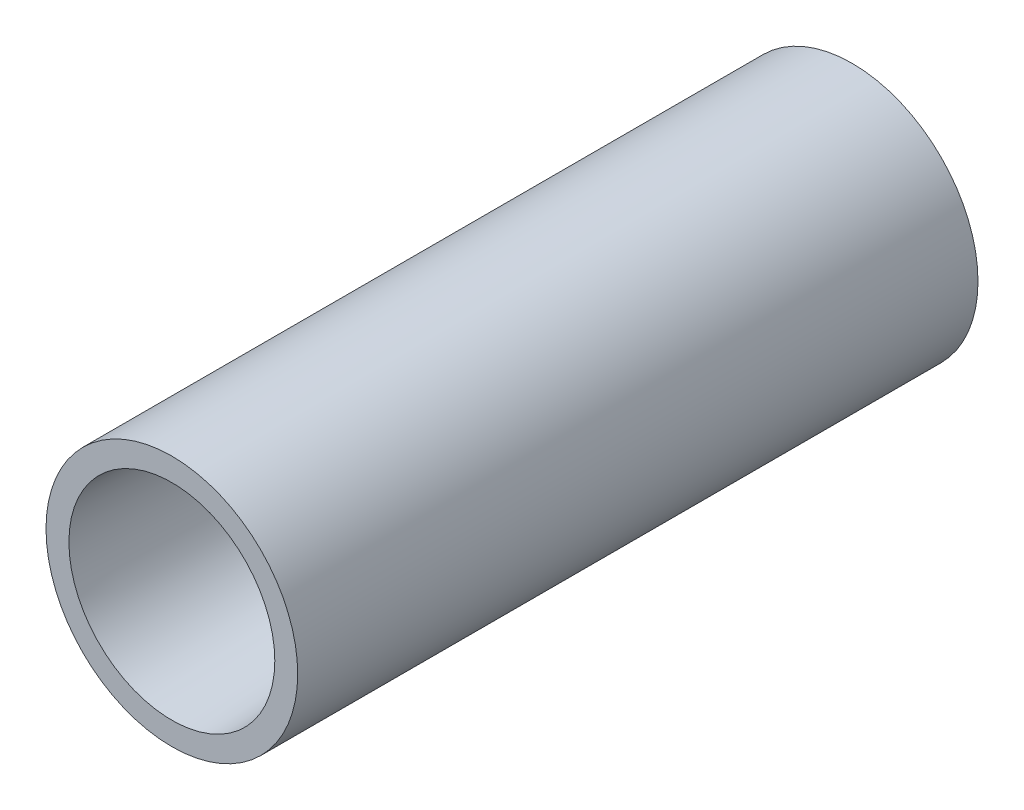
from build123d import *

# Parameters (mm, degrees)
SKETCH1_R           = 2.775
BOSS_EXTRUDE1_DEPTH = 15
SKETCH2_R           = 2.27
CUT_EXTRUDE1_DEPTH  = 5.68
CUT_EXTRUDE1_TAPER  = 3.074
SKETCH7_R           = 1
CUT_EXTRUDE2_DEPTH  = 16
SKETCH9_R           = 2.27
CUT_EXTRUDE3_DEPTH  = 5.68
CUT_EXTRUDE3_TAPER  = 3.074


with BuildPart() as part:
    # Sketch1 → Boss-Extrude1 (new body)
    with BuildSketch(Plane.XY):
        Circle(SKETCH1_R)
    extrude(amount=BOSS_EXTRUDE1_DEPTH)

    # Sketch2 → Cut-Extrude1 (cut)
    with BuildSketch(Plane.XY):
        Circle(SKETCH2_R)
    extrude(amount=CUT_EXTRUDE1_DEPTH, taper=CUT_EXTRUDE1_TAPER, mode=Mode.SUBTRACT)

    # Sketch7 → Cut-Extrude2 (cut, through all)
    with BuildSketch(Plane.XY):
        Circle(SKETCH7_R)
    extrude(amount=CUT_EXTRUDE2_DEPTH, mode=Mode.SUBTRACT)

    # Sketch9 → Cut-Extrude3 (cut)
    with BuildSketch(Plane.XY.offset(15)):
        Circle(SKETCH9_R)
    extrude(amount=-CUT_EXTRUDE3_DEPTH, taper=CUT_EXTRUDE3_TAPER, mode=Mode.SUBTRACT)


solid = part.part
